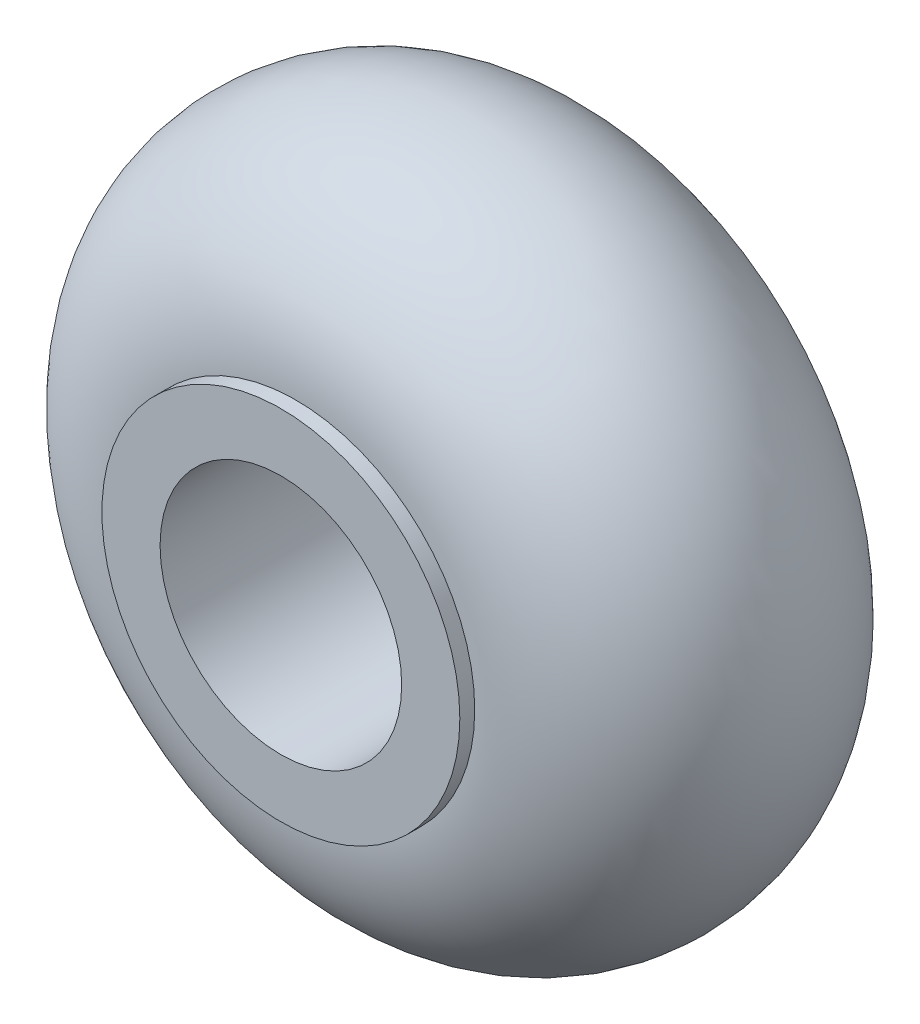
from build123d import *


with BuildPart() as part:
    # Sketch1 → Revolve1 (revolve)
    with BuildSketch(Plane(origin=(0, 0, 0), x_dir=(0, 0, -1), z_dir=(1, 0, 0))):
        with BuildLine():
            Line((-5.5, 6), (-6, 6))
            Line((-6, 6), (-6, 4.05))
            Line((-6, 4.05), (6, 4.05))
            Line((6, 4.05), (6, 6))
            Line((6, 6), (5.5, 6))
            ThreePointArc((5.5, 6), (0, 11.582338001), (-5.5, 6))
        make_face()
    revolve(axis=Axis((0, 0, 10.365384615), (0, 0, -1)))


solid = part.part
